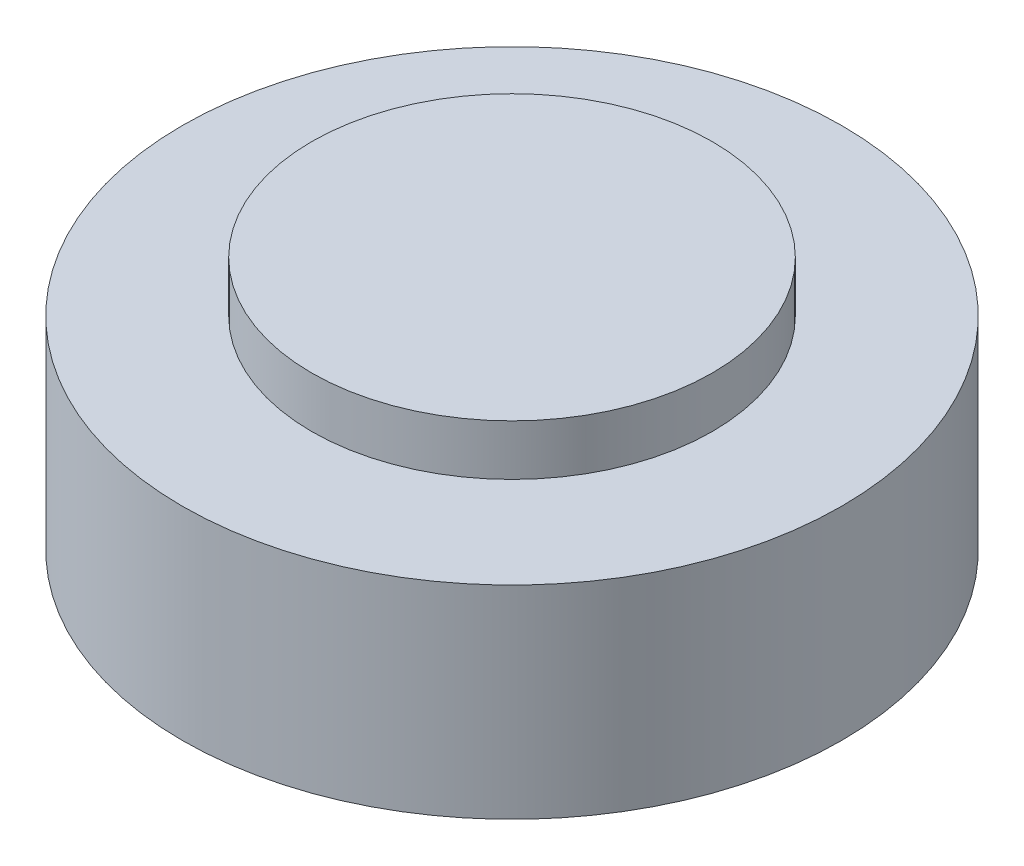
from build123d import *

# Parameters (mm, degrees)
CROQUIS2_R              = 7.9
SALIENTE_EXTRUIR1_DEPTH = 2
CROQUIS2_3_R            = 13
SALIENTE_EXTRUIR2_DEPTH = 8


with BuildPart() as part:
    # Croquis2 → Saliente-Extruir1 (new body)
    with BuildSketch(Plane(origin=(0, 0, 0), x_dir=(1, 0, 0), z_dir=(0, 1, 0))):
        Circle(CROQUIS2_R)
    extrude(amount=SALIENTE_EXTRUIR1_DEPTH)

    # Croquis2_3 → Saliente-Extruir2 (add)
    with BuildSketch(Plane(origin=(0, 0, 0), x_dir=(1, 0, 0), z_dir=(0, 1, 0))):
        Circle(CROQUIS2_3_R)
    extrude(amount=-SALIENTE_EXTRUIR2_DEPTH)


solid = part.part
